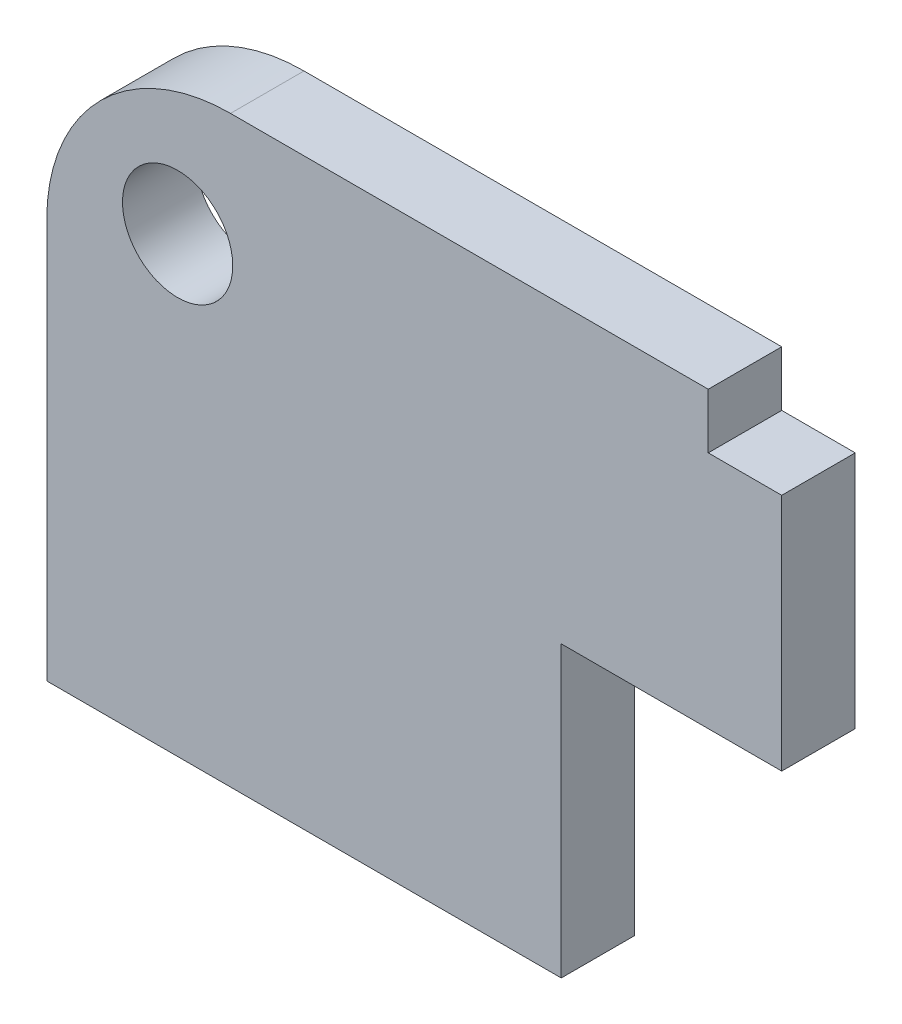
from build123d import *

# Parameters (mm, degrees)
SKETCH1_R           = 1.5
BOSS_EXTRUDE1_DEPTH = 2


with BuildPart() as part:
    # Sketch1 → Boss-Extrude1 (new body)
    with BuildSketch(Plane.XY):
        with BuildLine():
            Line((14, -8), (20, -8))
            Line((20, -8), (20, -1.5))
            Line((20, -1.5), (18, -1.5))
            Line((18, -1.5), (18, 0))
            Line((18, 0), (5, 0))
            ThreePointArc((5, 0), (1.464466094, -1.464466094), (0, -5))
            Line((0, -5), (0, -15.875626598))
            Line((0, -15.875626598), (14, -15.875626598))
            Line((14, -15.875626598), (14, -8))
        make_face()
        with Locations((3.560660172, -3.560660172)):
            Circle(SKETCH1_R, mode=Mode.SUBTRACT)
    extrude(amount=BOSS_EXTRUDE1_DEPTH)


solid = part.part
